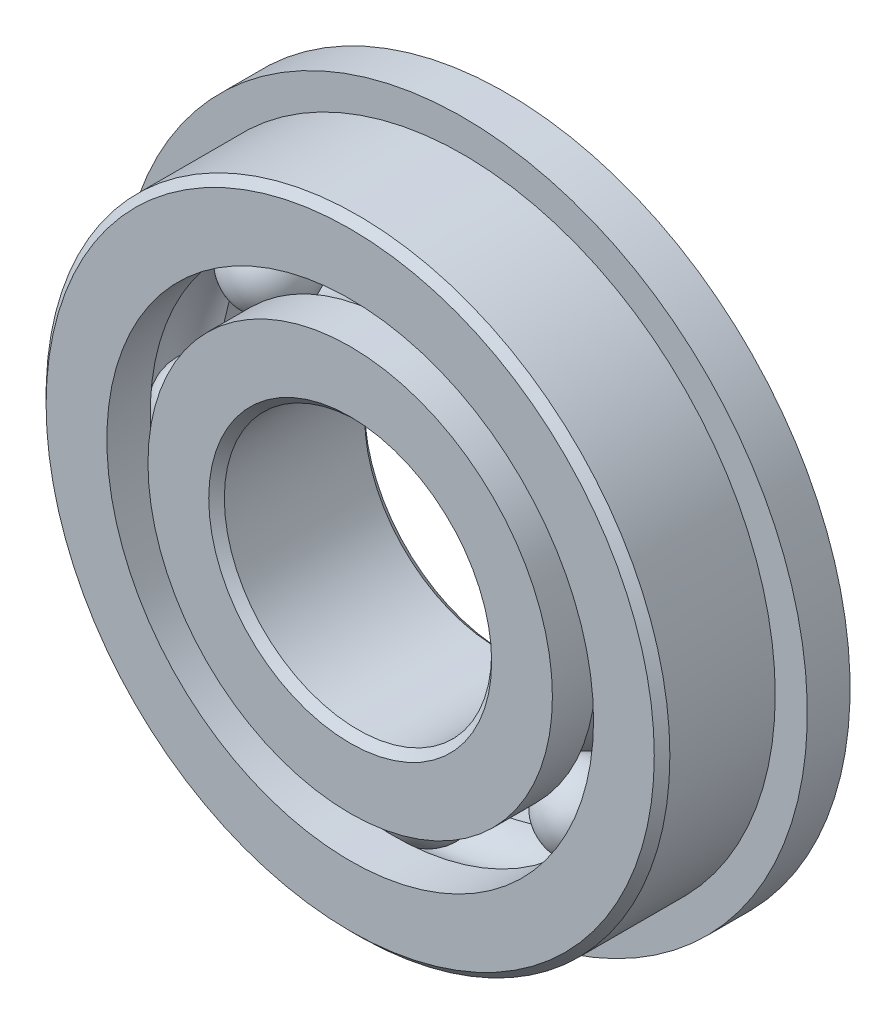
from build123d import *

# Parameters (mm, degrees)
CIRPATTERN1_COUNT = 8
SKETCH6_W         = 1.524
SKETCH6_H         = 3.585307692


with BuildPart() as part:
    # Sketch1 → Revolve1 (revolve)
    with BuildSketch(Plane(origin=(0, 0, 0), x_dir=(0, 0, -1), z_dir=(1, 0, 0))):
        with BuildLine():
            Line((2.5003125, 11.1125), (-2.5003125, 11.1125))
            Line((-2.5003125, 11.1125), (-2.778125, 10.8346875))
            Line((-2.778125, 10.8346875), (-2.778125, 8.670192308))
            Line((-2.778125, 8.670192308), (-1.234722222, 8.670192308))
            ThreePointArc((-1.234722222, 8.670192308), (0, 9.373249624), (1.234722222, 8.670192308))
            Line((1.234722222, 8.670192308), (2.778125, 8.670192308))
            Line((2.778125, 8.670192308), (2.778125, 10.8346875))
            Line((2.778125, 10.8346875), (2.5003125, 11.1125))
        make_face()
    revolve(axis=Axis((0, 0, 2.778125), (0, 0, -1)))

    # Sketch6 → Revolve6 (revolve)
    with BuildSketch(Plane(origin=(0, 0, 0), x_dir=(0, 0, -1), z_dir=(1, 0, 0))):
        with Locations((2.016125, 10.462846154)):
            Rectangle(SKETCH6_W, SKETCH6_H)
    revolve(axis=Axis((0, 0, -2.778125), (0, 0, 1)))


with BuildPart() as body_2:
    # Sketch3 → Revolve3 (revolve)
    with BuildSketch(Plane(origin=(0, 0, 0), x_dir=(0, 0, -1), z_dir=(1, 0, 0))):
        with BuildLine():
            Line((-2.778125, 7.204807692), (-1.234722222, 7.204807692))
            ThreePointArc((-1.234722222, 7.204807692), (0, 6.501750376), (1.234722222, 7.204807692))
            Line((1.234722222, 7.204807692), (2.778125, 7.204807692))
            Line((2.778125, 7.204807692), (2.778125, 5.0403125))
            Line((2.778125, 5.0403125), (2.5003125, 4.7625))
            Line((2.5003125, 4.7625), (-2.5003125, 4.7625))
            Line((-2.5003125, 4.7625), (-2.778125, 5.0403125))
            Line((-2.778125, 5.0403125), (-2.778125, 7.204807692))
        make_face()
    revolve(axis=Axis((0, 0, 2.778125), (0, 0, -1)))


with BuildPart() as body_3:
    # Sketch4 → Revolve4 (revolve)
    with BuildSketch(Plane(origin=(0, 0, 0), x_dir=(0, 0, -1), z_dir=(1, 0, 0))):
        with BuildLine():
            Line((-1.435749624, 7.9375), (1.435749624, 7.9375))
            ThreePointArc((1.435749624, 7.9375), (0, 9.373249624), (-1.435749624, 7.9375))
        make_face()
    revolve(axis=Axis((0, 7.9375, 1.435749624), (0, 0, -1)))


with BuildPart() as cirpattern1_1:
    # CirPattern1: pattern copy
    add(body_3.part.rotate(Axis((0, 0, -2.778125), (0, 0, 1)), 1 * 360 / CIRPATTERN1_COUNT))


with BuildPart() as cirpattern1_2:
    # CirPattern1: pattern copy
    add(body_3.part.rotate(Axis((0, 0, -2.778125), (0, 0, 1)), 2 * 360 / CIRPATTERN1_COUNT))


with BuildPart() as cirpattern1_3:
    # CirPattern1: pattern copy
    add(body_3.part.rotate(Axis((0, 0, -2.778125), (0, 0, 1)), 3 * 360 / CIRPATTERN1_COUNT))


with BuildPart() as cirpattern1_4:
    # CirPattern1: pattern copy
    add(body_3.part.rotate(Axis((0, 0, -2.778125), (0, 0, 1)), 4 * 360 / CIRPATTERN1_COUNT))


with BuildPart() as cirpattern1_5:
    # CirPattern1: pattern copy
    add(body_3.part.rotate(Axis((0, 0, -2.778125), (0, 0, 1)), 5 * 360 / CIRPATTERN1_COUNT))


with BuildPart() as cirpattern1_6:
    # CirPattern1: pattern copy
    add(body_3.part.rotate(Axis((0, 0, -2.778125), (0, 0, 1)), 6 * 360 / CIRPATTERN1_COUNT))


with BuildPart() as cirpattern1_7:
    # CirPattern1: pattern copy
    add(body_3.part.rotate(Axis((0, 0, -2.778125), (0, 0, 1)), 7 * 360 / CIRPATTERN1_COUNT))


solid = Compound([part.part, body_2.part, body_3.part, cirpattern1_1.part, cirpattern1_2.part, cirpattern1_3.part, cirpattern1_4.part, cirpattern1_5.part, cirpattern1_6.part, cirpattern1_7.part])
